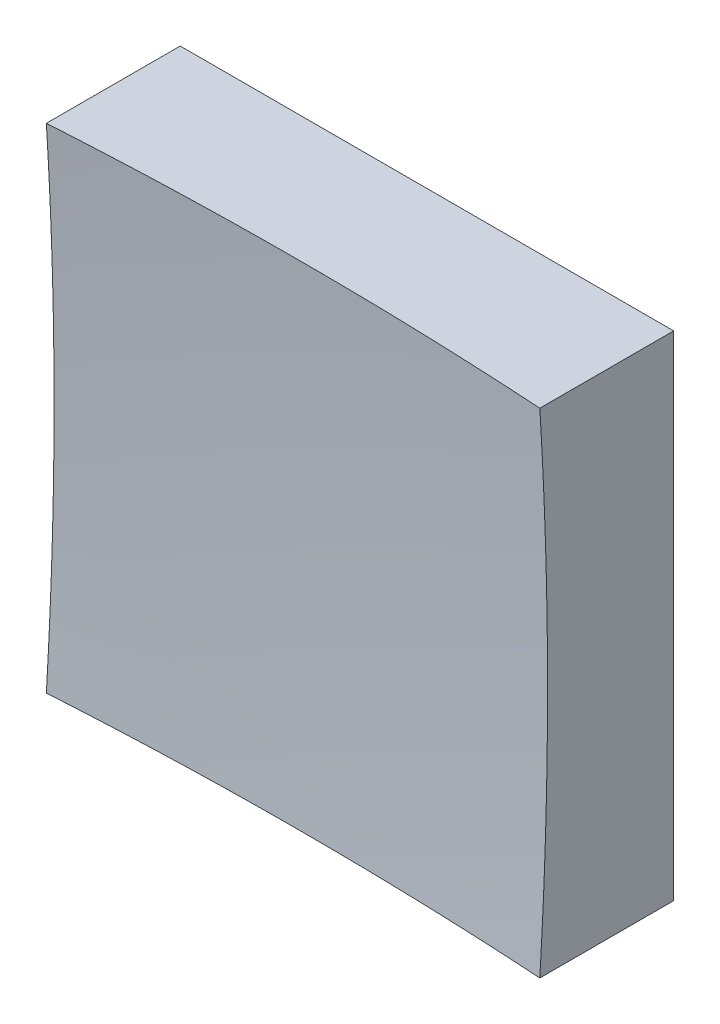
from build123d import *

# Parameters (mm, degrees)
SKETCH_1_W      = 25
SKETCH_1_H      = 25
EXTRUDE_1_DEPTH = 20


with BuildPart() as part:
    # 草图1 → 凸台-拉伸1 (new body)
    with BuildSketch(Plane.XY):
        Rectangle(SKETCH_1_W, SKETCH_1_H)
    extrude(amount=EXTRUDE_1_DEPTH)

    # 草图2 → 切除-旋转2 (revolve, cut)
    with BuildSketch(Plane(origin=(0, 0, 0), x_dir=(1, 0, 0), z_dir=(0, 1, 0))):
        with BuildLine():
            Line((194.969092363, -161.423627073), (0, -161.423627073))
            Line((0, -161.423627073), (0, -6))
            ThreePointArc((0, -6), (124.669012619, -49.610622827), (194.969092363, -161.423627073))
        make_face()
    revolve(axis=Axis((0, 0, 161.423627073), (0, 0, -1)), mode=Mode.SUBTRACT)


solid = part.part
